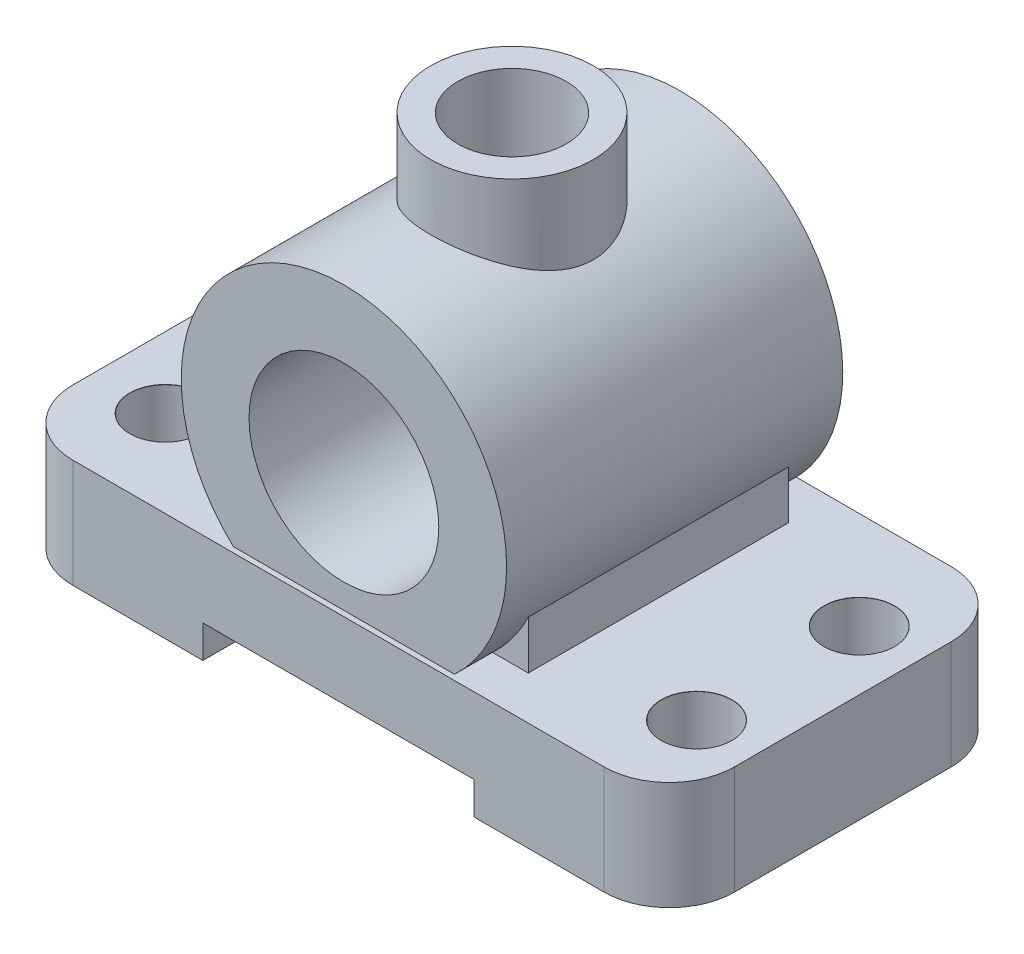
from build123d import *

# Parameters (mm, degrees)
EXTRUDE_12_DEPTH                  = 20
SKETCH_13_W                       = 54
SKETCH_13_H                       = 48
EXTRUDE_13_DEPTH                  = 22
EXTRUDE_START                     = -55
SKETCH_14_R                       = 30
EXTRUDE_14_DEPTH                  = 62
SKETCH_19_W                       = 50
SKETCH_19_H                       = 12
CUT_EXTRUDE_3_DEPTH               = 1
CUT_EXTRUDE_3_DEPTH_BACK          = 65
EXTRUDE_START_2                   = 6
SKETCH_20_R                       = 15
EXTRUDE_17_DEPTH                  = 78
SKETCH_21_R                       = 10
CUT_EXTRUDE_4_DEPTH               = 1.0000001
CUT_EXTRUDE_4_DEPTH_BACK          = 85
SKETCH_23_R                       = 17.5
CUT_EXTRUDE_7_DEPTH               = 48
SKETCH_25_R                       = 10
CUT_EXTRUDE_8_DEPTH               = 17
HOLE_WIZARD_13_0_13_2_D           = 13
HOLE_WIZARD_13_0_13_2_CSINK_D     = 13.05
HOLE_WIZARD_13_0_13_2_CSINK_ANGLE = 90


with BuildPart() as part:
    # Эскиз12 → Бобышка-Вытянуть12 (new body)
    with BuildSketch(Plane(origin=(0, 0, 0), x_dir=(1, 0, 0), z_dir=(0, 1, 0))):
        with BuildLine():
            Line((-49, -32), (49, -32))
            ThreePointArc((49, -32), (57.485281374, -28.485281374), (61, -20))
            Line((61, -20), (61, 20))
            ThreePointArc((61, 20), (57.485281374, 28.485281374), (49, 32))
            Line((49, 32), (-49, 32))
            ThreePointArc((-49, 32), (-57.485281374, 28.485281374), (-61, 20))
            Line((-61, 20), (-61, -20))
            ThreePointArc((-61, -20), (-57.485281374, -28.485281374), (-49, -32))
        make_face()
    extrude(amount=EXTRUDE_12_DEPTH)

    # Эскиз13 → Бобышка-Вытянуть13 (add)
    with BuildSketch(Plane(origin=(0, 20, 0), x_dir=(1, 0, 0), z_dir=(0, 1, 0))):
        Rectangle(SKETCH_13_W, SKETCH_13_H)
    extrude(amount=EXTRUDE_13_DEPTH)

    # Эскиз14 → Бобышка-Вытянуть14 (add)
    with BuildSketch(Plane.XY.offset(24).offset(EXTRUDE_START)):
        with Locations((0, 42)):
            Circle(SKETCH_14_R)
    extrude(amount=EXTRUDE_14_DEPTH)

    # Эскиз19 → Вырез-Вытянуть3 (cut, two sides)
    with BuildSketch(Plane.XY.offset(32)) as cut_extrude_3_sk:
        Rectangle(SKETCH_19_W, SKETCH_19_H)
    extrude(amount=CUT_EXTRUDE_3_DEPTH, mode=Mode.SUBTRACT)
    extrude(cut_extrude_3_sk.sketch, amount=-CUT_EXTRUDE_3_DEPTH_BACK, mode=Mode.SUBTRACT)

    # Эскиз20 → Бобышка-Вытянуть17 (add)
    with BuildSketch(Plane(origin=(0, 0, 0), x_dir=(1, 0, 0), z_dir=(0, 1, 0)).offset(EXTRUDE_START_2)):
        Circle(SKETCH_20_R)
    extrude(amount=EXTRUDE_17_DEPTH)

    # Эскиз21 → Вырез-Вытянуть4 (cut, two sides)
    with BuildSketch(Plane(origin=(0, 84, 0), x_dir=(1, 0, 0), z_dir=(0, 1, 0))) as cut_extrude_4_sk:
        Circle(SKETCH_21_R)
    extrude(amount=CUT_EXTRUDE_4_DEPTH, mode=Mode.SUBTRACT)
    extrude(cut_extrude_4_sk.sketch, amount=-CUT_EXTRUDE_4_DEPTH_BACK, mode=Mode.SUBTRACT)

    # Эскиз23 → Вырез-Вытянуть7 (cut)
    with BuildSketch(Plane.XY.offset(31)):
        with Locations((0, 42)):
            Circle(SKETCH_23_R)
    extrude(amount=-CUT_EXTRUDE_7_DEPTH, mode=Mode.SUBTRACT)

    # Эскиз25 → Вырез-Вытянуть8 (cut)
    with BuildSketch(Plane(origin=(0, 0, -31), x_dir=(-1, 0, 0), z_dir=(0, 0, -1))):
        with Locations((0, 42)):
            Circle(SKETCH_25_R)
    extrude(amount=-CUT_EXTRUDE_8_DEPTH, mode=Mode.SUBTRACT)

    # Диаметр отверстия Ø13.0 (13)2 (through all)
    with Locations(Plane(origin=(0, 20, 0), x_dir=(1, 0, 0), z_dir=(0, 1, 0))):
        with Locations((-47.963392627, 14), (-47.963392627, -16), (50.036607373, -16), (50.036607373, 14)):
            CounterSinkHole(HOLE_WIZARD_13_0_13_2_D / 2, HOLE_WIZARD_13_0_13_2_CSINK_D / 2, counter_sink_angle=HOLE_WIZARD_13_0_13_2_CSINK_ANGLE)


solid = part.part
